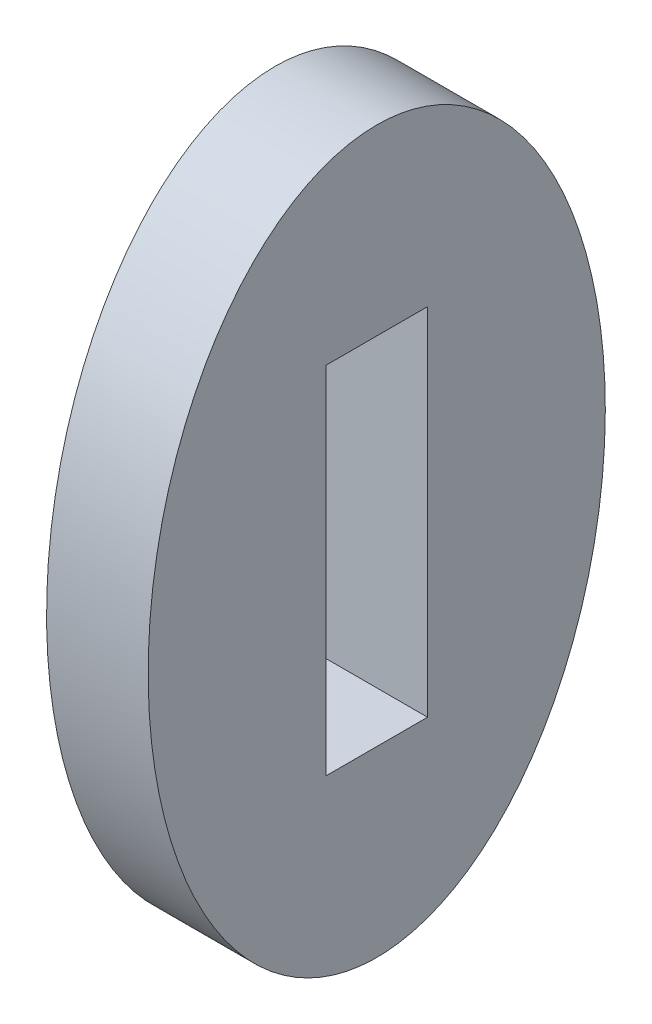
from build123d import *

# Parameters (mm, degrees)
SKETCH1_RX          = 22.536539577
SKETCH1_RY          = 14.2875
SKETCH1_W           = 6.35
SKETCH1_H           = 22.225
BOSS_EXTRUDE1_DEPTH = 6.35


with BuildPart() as part:
    # Sketch1 → Boss-Extrude1 (new body)
    with BuildSketch(Plane(origin=(0, 0, 0), x_dir=(0, 0, -1), z_dir=(1, 0, 0))):
        with Locations(Location((0, 0), (0, 0, 90))):
            Ellipse(SKETCH1_RX, SKETCH1_RY)
        Rectangle(SKETCH1_W, SKETCH1_H, mode=Mode.SUBTRACT)
    extrude(amount=BOSS_EXTRUDE1_DEPTH)


solid = part.part
